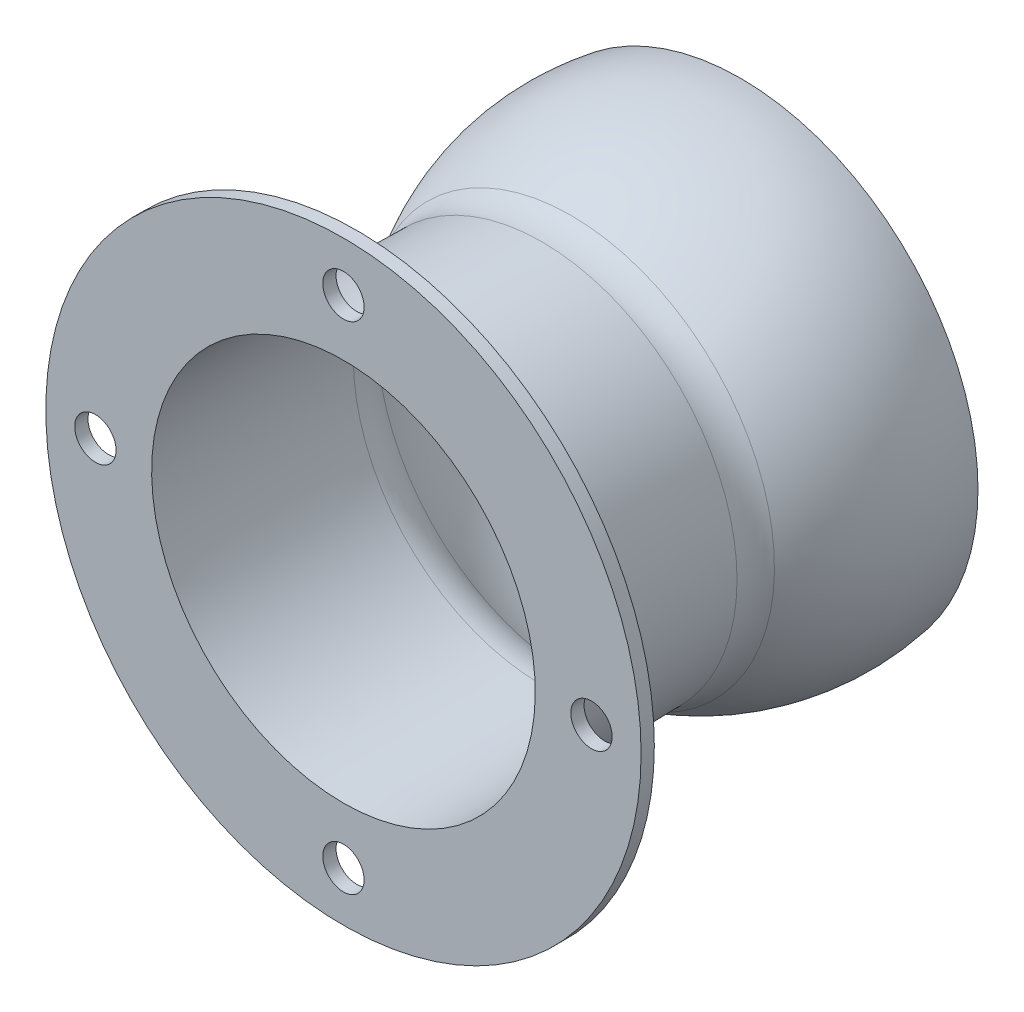
from build123d import *

# Parameters (mm, degrees)
SHELL1_T            = -1
SKETCH2_R           = 45
SKETCH2_R_2         = 3.125
SKETCH2_R_3         = 28.999861121
BOSS_EXTRUDE1_DEPTH = 2


with BuildPart() as part:
    # Sketch1 → Revolve1 (revolve)
    with BuildSketch(Plane(origin=(0, 0, 0), x_dir=(0, 0, -1), z_dir=(1, 0, 0))):
        with BuildLine():
            Line((0, 0), (-50.959835356, 0))
            Line((-50.959835356, 0), (-60.054255014, 0))
            Line((-60.054255014, 0), (-60.054255014, 30))
            Line((-60.054255014, 30), (-30.054255014, 29.5))
            ThreePointArc((-30.054255014, 29.5), (-27.754838856, 29.797720054), (-25.637373582, 30.742332522))
            ThreePointArc((-25.637373582, 30.742332522), (-22.902920152, 32.314145749), (-20.042663952, 33.643343571))
            ThreePointArc((-20.042663952, 33.643343571), (-10.179122164, 36.1760026), (0, 35.877187771))
            Line((0, 35.877187771), (0, 34.862194457))
            Line((0, 34.862194457), (0, 0))
        make_face()
    revolve(axis=Axis((0, 0, 0), (0, 0, 1)))

    # Shell1
    shell1_openings = [part.faces().sort_by_distance(p)[0] for p in [
        (0, 0, 0),
        (0, 0, 60.054255014),
    ]]
    offset(amount=SHELL1_T, openings=shell1_openings, kind=Kind.INTERSECTION)

    # Sketch2 → Boss-Extrude1 (add)
    with BuildSketch(Plane.XY.offset(60.054255014)):
        Circle(SKETCH2_R)
        with Locations((0, 37.5)):
            Circle(SKETCH2_R_2, mode=Mode.SUBTRACT)
        with Locations((37.5, 0)):
            Circle(SKETCH2_R_2, mode=Mode.SUBTRACT)
        with Locations((0, -37.5)):
            Circle(SKETCH2_R_2, mode=Mode.SUBTRACT)
        with Locations((-37.5, 0)):
            Circle(SKETCH2_R_2, mode=Mode.SUBTRACT)
        Circle(SKETCH2_R_3, mode=Mode.SUBTRACT)
    extrude(amount=-BOSS_EXTRUDE1_DEPTH)


solid = part.part
